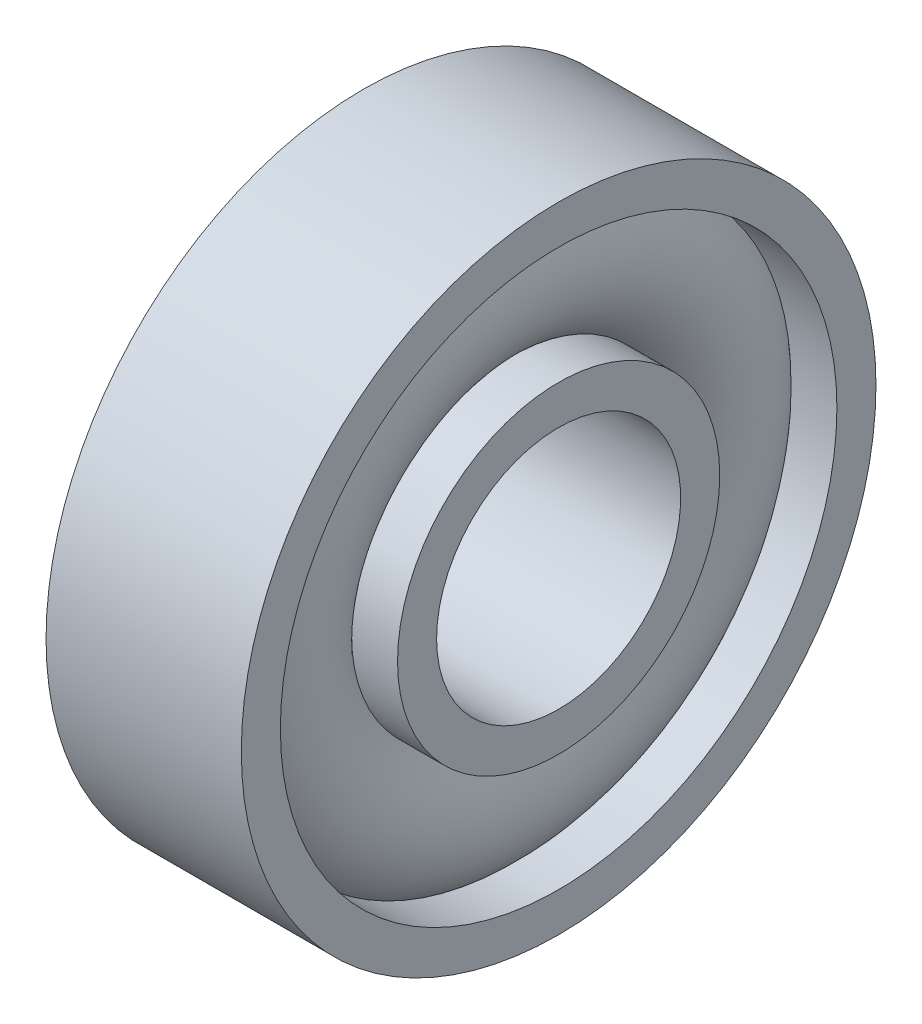
from build123d import *


with BuildPart() as part:
    # Esquisse1 → Révolution1 (revolve)
    with BuildSketch(Plane.XY):
        with BuildLine():
            Line((-2, 6.5), (2, 6.5))
            Line((2, 6.5), (2, 5.7))
            Line((2, 5.7), (1.058300524, 5.7))
            ThreePointArc((1.058300524, 5.7), (1.6, 4.5), (1.058300524, 3.3))
            Line((1.058300524, 3.3), (2, 3.3))
            Line((2, 3.3), (2, 2.5))
            Line((2, 2.5), (-2, 2.5))
            Line((-2, 2.5), (-2, 3.3))
            Line((-2, 3.3), (-1.058300524, 3.3))
            ThreePointArc((-1.058300524, 3.3), (-1.6, 4.5), (-1.058300524, 5.7))
            Line((-1.058300524, 5.7), (-2, 5.7))
            Line((-2, 5.7), (-2, 6.5))
        make_face()
    revolve(axis=Axis((-3.50151098, 0, 0), (1, 0, 0)))


solid = part.part
